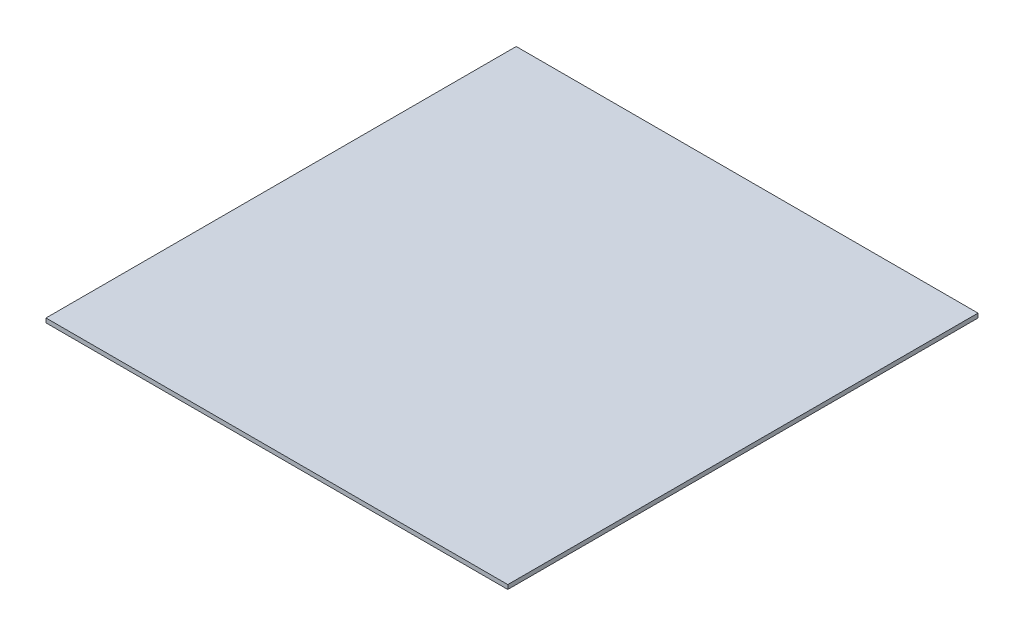
from build123d import *

# Parameters (mm, degrees)
SKETCH1_W      = 2740
SKETCH1_H      = 2790
EXTRUDE1_DEPTH = 25.4


with BuildPart() as part:
    # Sketch1 → Extrude1 (new body)
    with BuildSketch(Plane(origin=(0, 0, 0), x_dir=(1, 0, 0), z_dir=(0, 1, 0))):
        with Locations((1370, 4.55249367)):
            Rectangle(SKETCH1_W, SKETCH1_H)
    extrude(amount=EXTRUDE1_DEPTH)


solid = part.part
